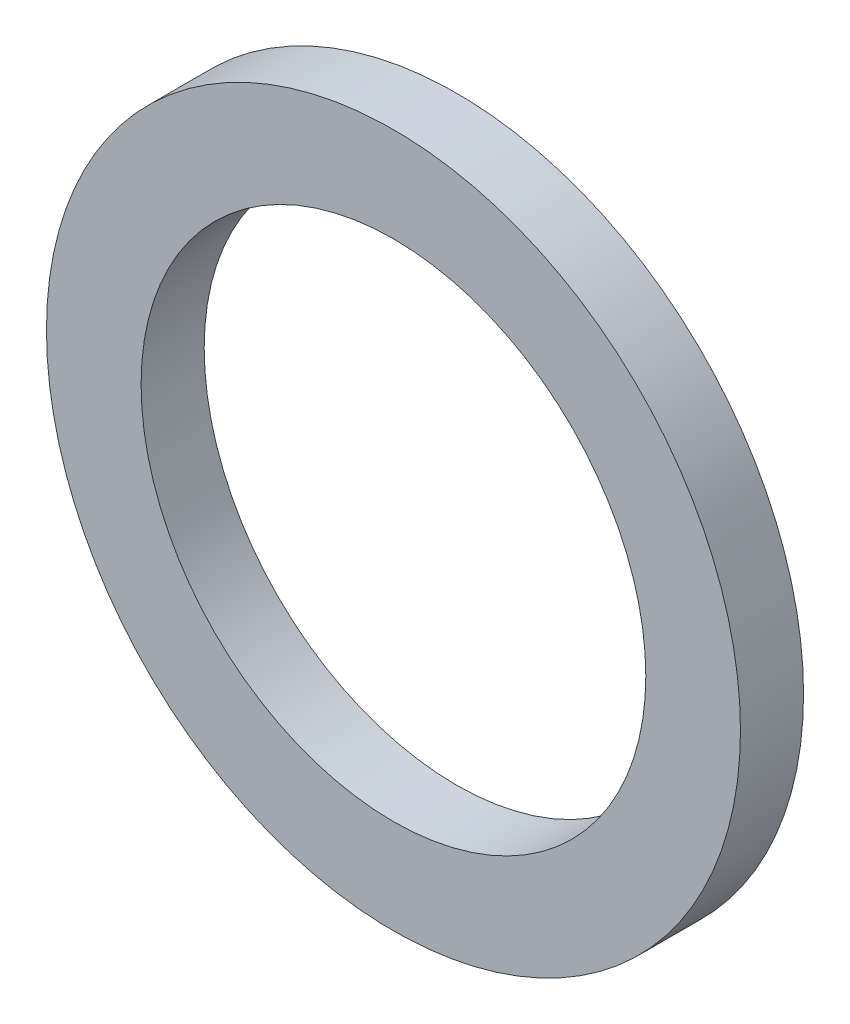
from build123d import *

# Parameters (mm, degrees)
SKETCH1_R           = 5.5
SKETCH1_R_2         = 4
EXTRUDE_THIN1_DEPTH = 1


with BuildPart() as part:
    # Sketch1 → Extrude-Thin1 (new body)
    with BuildSketch(Plane.XY):
        Circle(SKETCH1_R)
        Circle(SKETCH1_R_2, mode=Mode.SUBTRACT)
    extrude(amount=EXTRUDE_THIN1_DEPTH)


solid = part.part
